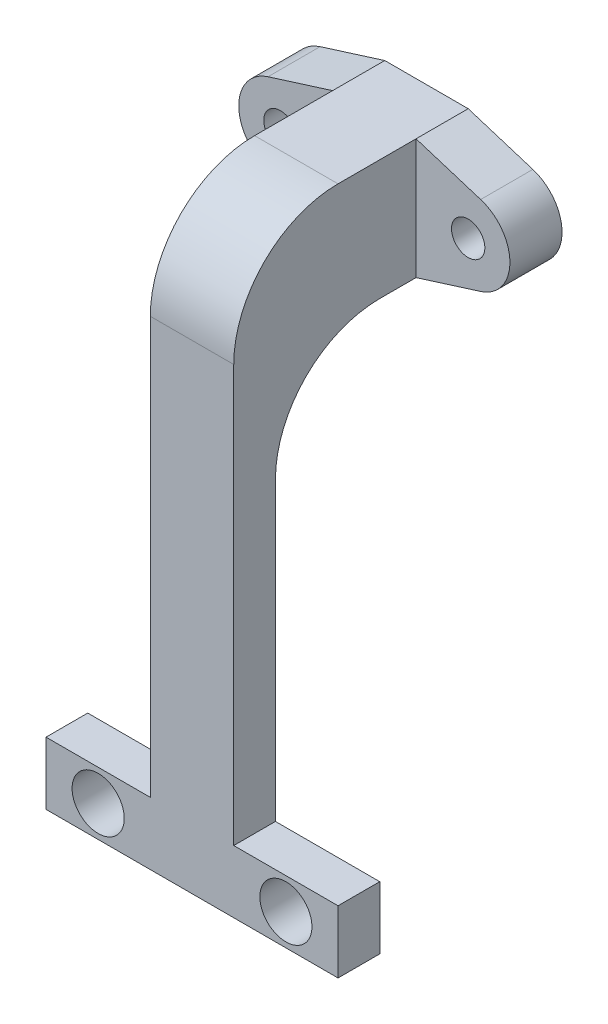
from build123d import *

# Parameters (mm, degrees)
ESBO_O1_R                = 1.598160281
ESBO_O1_R_2              = 1.600993429
RESSALTO_EXTRUS_O1_DEPTH = 5
ESBO_O2_W                = 8.00000038
ESBO_O2_H                = 11.528000702
RESSALTO_EXTRUS_O2_DEPTH = 17.480363
ESBO_O3_W                = 8.00000038
ESBO_O3_H                = 4
RESSALTO_EXTRUS_O3_DEPTH = 44.418848
ESBO_O4_W                = 4
ESBO_O4_H                = 6.000686184
RESSALTO_EXTRUS_O4_DEPTH = 10
ESBO_O5_W                = 4
ESBO_O5_H                = 6
RESSALTO_EXTRUS_O5_DEPTH = 10
FILETE1_R                = 10
FILETE2_R                = 10
ESBO_O6_R                = 2.5
CORTE_EXTRUS_O1_DEPTH    = 10


with BuildPart() as part:
    # Esboço1 → Ressalto-extrusão1 (new body)
    with BuildSketch(Plane.XY):
        with BuildLine():
            Line((-10.199065979, -3.817665654), (-4.00000019, -5.764999893))
            Line((-4.00000019, -5.764999893), (4.00000019, -5.764999893))
            Line((4.00000019, -5.764999893), (10.197782, -3.817301838))
            ThreePointArc((10.197782, -3.817301838), (12.999977706, 0.001566069), (10.195969576, 3.8191034))
            Line((10.195969576, 3.8191034), (4.00000019, 5.763000809))
            Line((4.00000019, 5.763000809), (-4.00000019, 5.763000809))
            Line((-4.00000019, 5.763000809), (-10.199143851, 3.815503142))
            ThreePointArc((-10.199143851, 3.815503142), (-13.000622723, -0.001109837), (-10.199065979, -3.817665654))
        make_face()
        with Locations((8.997973452, 0.000616233)):
            Circle(ESBO_O1_R, mode=Mode.SUBTRACT)
        with Locations((-9.000145119, -0.001069025)):
            Circle(ESBO_O1_R_2, mode=Mode.SUBTRACT)
    extrude(amount=RESSALTO_EXTRUS_O1_DEPTH)

    # Esboço2 → Ressalto-extrusão2 (add)
    with BuildSketch(Plane.XY.offset(5)):
        with Locations((0, -0.000999542)):
            Rectangle(ESBO_O2_W, ESBO_O2_H)
    extrude(amount=RESSALTO_EXTRUS_O2_DEPTH)

    # Esboço3 → Ressalto-extrusão3 (add)
    with BuildSketch(Plane.XZ.offset(5.764999893)):
        with Locations((0, 20.480363203)):
            Rectangle(ESBO_O3_W, ESBO_O3_H)
    extrude(amount=RESSALTO_EXTRUS_O3_DEPTH)

    # Esboço4 → Ressalto-extrusão4 (add)
    with BuildSketch(Plane.ZY.offset(4.00000019)):
        with Locations((20.480363203, -47.183504361)):
            Rectangle(ESBO_O4_W, ESBO_O4_H)
    extrude(amount=RESSALTO_EXTRUS_O4_DEPTH)

    # Esboço5 → Ressalto-extrusão5 (add)
    with BuildSketch(Plane(origin=(4.00000019, 0, 0), x_dir=(0, 0, -1), z_dir=(1, 0, 0))):
        with Locations((-20.480363203, -47.183847453)):
            Rectangle(ESBO_O5_W, ESBO_O5_H)
    extrude(amount=RESSALTO_EXTRUS_O5_DEPTH)

    # Filete1
    filete1_edges = [part.edges().sort_by_distance(p)[0] for p in [
        (0, -5.764999893, 18.480363203),
    ]]
    fillet(filete1_edges, radius=FILETE1_R)

    # Filete2
    filete2_edges = [part.edges().sort_by_distance(p)[0] for p in [
        (0, 5.763000809, 22.480363),
    ]]
    fillet(filete2_edges, radius=FILETE2_R)

    # Esboço6 → Corte-extrusão1 (cut)
    with BuildSketch(Plane(origin=(0, 0, 18.480363203), x_dir=(-1, 0, 0), z_dir=(0, 0, -1))):
        with Locations((-9.00000019, -47.183786187)):
            Circle(ESBO_O6_R)
        with Locations((9.00000019, -47.183565627)):
            Circle(ESBO_O6_R)
    extrude(amount=-CORTE_EXTRUS_O1_DEPTH, mode=Mode.SUBTRACT)


solid = part.part
